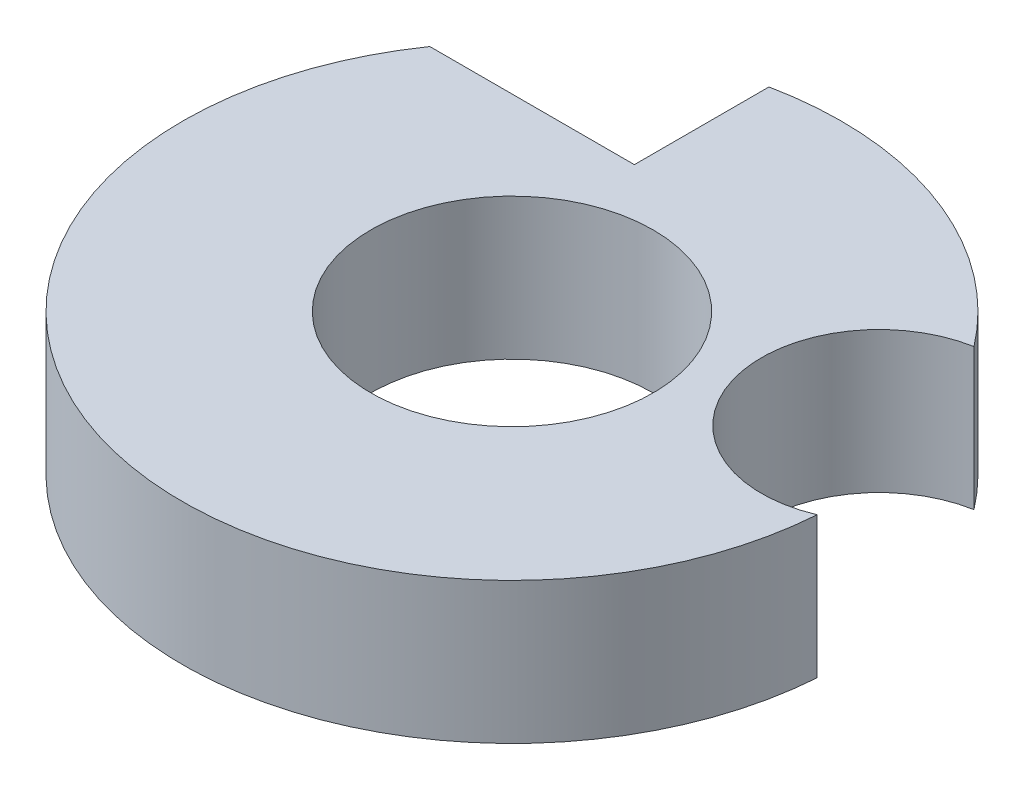
from build123d import *

# Parameters (mm, degrees)
SKETCH_1_W          = 2
SKETCH_1_H          = 1.5
CUT_EXTRUDE_1_DEPTH = 6.172040216


with BuildPart() as part:
    # Эскиз1 → Повернуть1 (revolve)
    with BuildSketch(Plane.XY, mode=Mode.PRIVATE) as revolve_1_sk:
        with Locations((2.5, 0.75)):
            Rectangle(SKETCH_1_W, SKETCH_1_H)
    revolve(revolve_1_sk.sketch.rotate(Axis((0, 0, 0), (0, 1, 0)), 90), axis=Axis((0, 0, 0), (0, 1, 0)))

    # Эскиз2 → Вырез-Вытянуть1 (cut, through all)
    with BuildSketch(Plane(origin=(0, 1.5, 0), x_dir=(1, 0, 0), z_dir=(0, 1, 0))):
        with BuildLine():
            Line((-0.7, 2), (-0.7, 3.42928564))
            ThreePointArc((-0.7, 3.42928564), (-1.923801659, 2.923865109), (-2.872281323, 2))
            Line((-2.872281323, 2), (-0.7, 2))
        make_face()
        with BuildLine():
            ThreePointArc((3.491096592, -0.249488641), (3.352391998, 1.005717599), (2.777252031, 2.129993229))
            ThreePointArc((2.777252031, 2.129993229), (1.802717143, 0.540815143), (3.491096592, -0.249488641))
        make_face()
    extrude(amount=-CUT_EXTRUDE_1_DEPTH, mode=Mode.SUBTRACT)


solid = part.part
